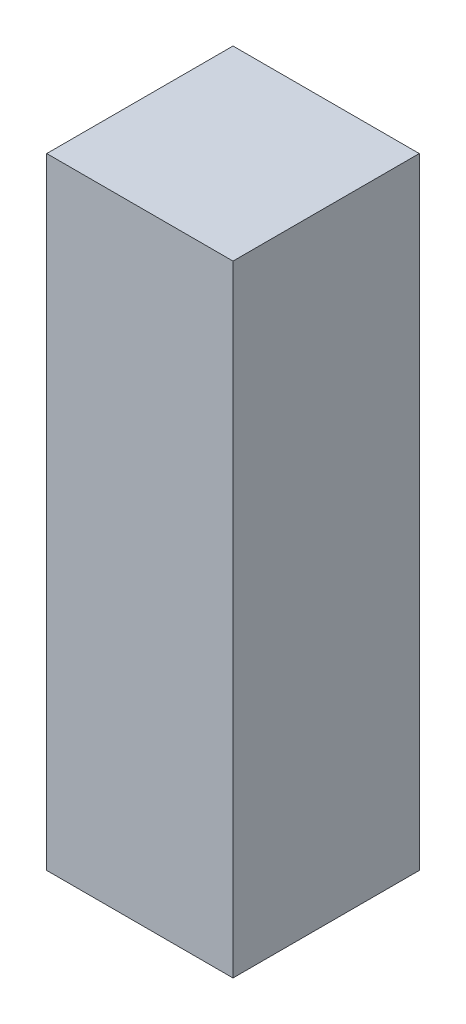
from build123d import *

# Parameters (mm, degrees)
SKETCH1_W           = 17.145
SKETCH1_H           = 17.145
BOSS_EXTRUDE1_DEPTH = 28.575


with BuildPart() as part:
    # Sketch1 → Boss-Extrude1 (new body, symmetric)
    with BuildSketch(Plane(origin=(0, 0, 0), x_dir=(1, 0, 0), z_dir=(0, 1, 0))):
        Rectangle(SKETCH1_W, SKETCH1_H)
    extrude(amount=BOSS_EXTRUDE1_DEPTH, both=True)


solid = part.part
